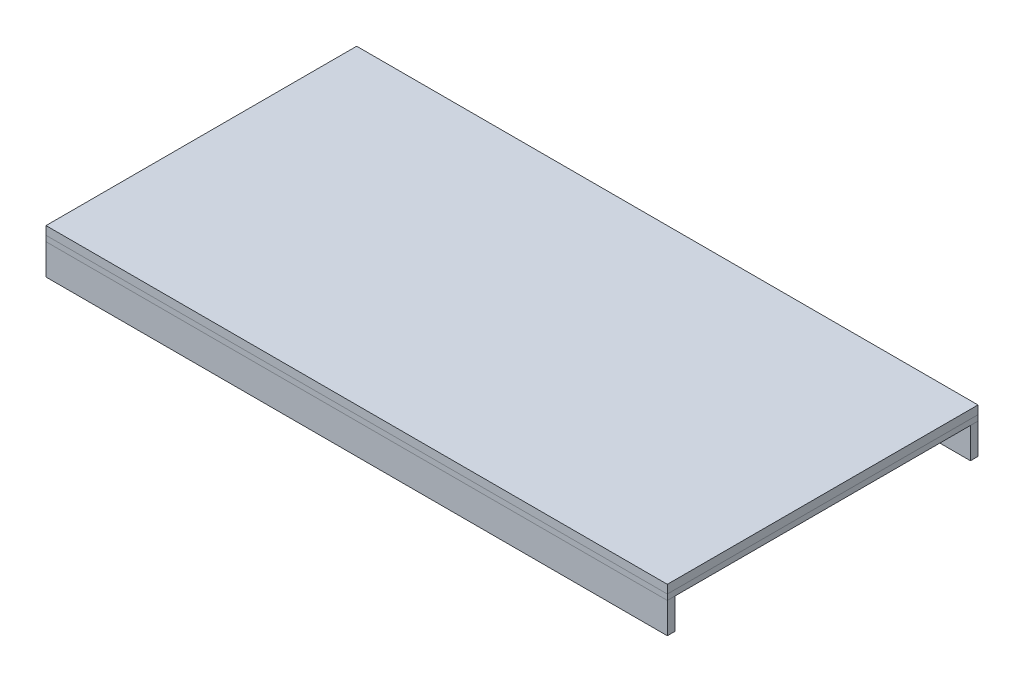
from build123d import *

# Parameters (mm, degrees)
SKETCH1_W             = 1400
SKETCH1_H             = 700
BOSS_EXTRUDE1_DEPTH   = 19
SKETCH2_W             = 1400
SKETCH2_H             = 700
BOSS_EXTRUDE2_DEPTH   = 12.5
SKETCH3_W             = 17
SKETCH3_H             = 69
BOSS_EXTRUDE3_DEPTH   = 1400
BOSS_EXTRUDE3_2_DEPTH = 1400
SKETCH4_W             = 12.5
SKETCH4_H             = 69
BOSS_EXTRUDE4_DEPTH   = 666
BOSS_EXTRUDE4_2_DEPTH = 666
BOSS_EXTRUDE4_3_DEPTH = 666


with BuildPart() as part:
    # Sketch1 → Boss-Extrude1 (new body)
    with BuildSketch(Plane(origin=(0, 0, 0), x_dir=(1, 0, 0), z_dir=(0, 1, 0))):
        Rectangle(SKETCH1_W, SKETCH1_H)
    extrude(amount=-BOSS_EXTRUDE1_DEPTH)


with BuildPart() as body_2:
    # Sketch2 → Boss-Extrude2 (new body)
    with BuildSketch(Plane.XZ.offset(19)):
        Rectangle(SKETCH2_W, SKETCH2_H)
    extrude(amount=BOSS_EXTRUDE2_DEPTH)


with BuildPart() as body_3:
    # Sketch3 → Boss-Extrude3 (new body)
    with BuildSketch(Plane(origin=(700, 0, 0), x_dir=(0, 0, -1), z_dir=(1, 0, 0))):
        with Locations((-341.5, -66)):
            Rectangle(SKETCH3_W, SKETCH3_H)
    extrude(amount=-BOSS_EXTRUDE3_DEPTH)


with BuildPart() as body_4:
    # Sketch3 → Boss-Extrude3 2 (new body)
    with BuildSketch(Plane(origin=(700, 0, 0), x_dir=(0, 0, -1), z_dir=(1, 0, 0))):
        with Locations((341.5, -66)):
            Rectangle(SKETCH3_W, SKETCH3_H)
    extrude(amount=-BOSS_EXTRUDE3_2_DEPTH)


with BuildPart() as body_5:
    # Sketch4 → Boss-Extrude4 (new body)
    with BuildSketch(Plane.XY.offset(-333)):
        with Locations((0, -66)):
            Rectangle(SKETCH4_W, SKETCH4_H)
    extrude(amount=BOSS_EXTRUDE4_DEPTH)


with BuildPart() as body_6:
    # Sketch4 → Boss-Extrude4 2 (new body)
    with BuildSketch(Plane.XY.offset(-333)):
        with Locations((350, -66)):
            Rectangle(SKETCH4_W, SKETCH4_H)
    extrude(amount=BOSS_EXTRUDE4_2_DEPTH)


with BuildPart() as body_7:
    # Sketch4 → Boss-Extrude4 3 (new body)
    with BuildSketch(Plane.XY.offset(-333)):
        with Locations((-350, -66)):
            Rectangle(SKETCH4_W, SKETCH4_H)
    extrude(amount=BOSS_EXTRUDE4_3_DEPTH)


solid = Compound([part.part, body_2.part, body_3.part, body_4.part, body_5.part, body_6.part, body_7.part])
